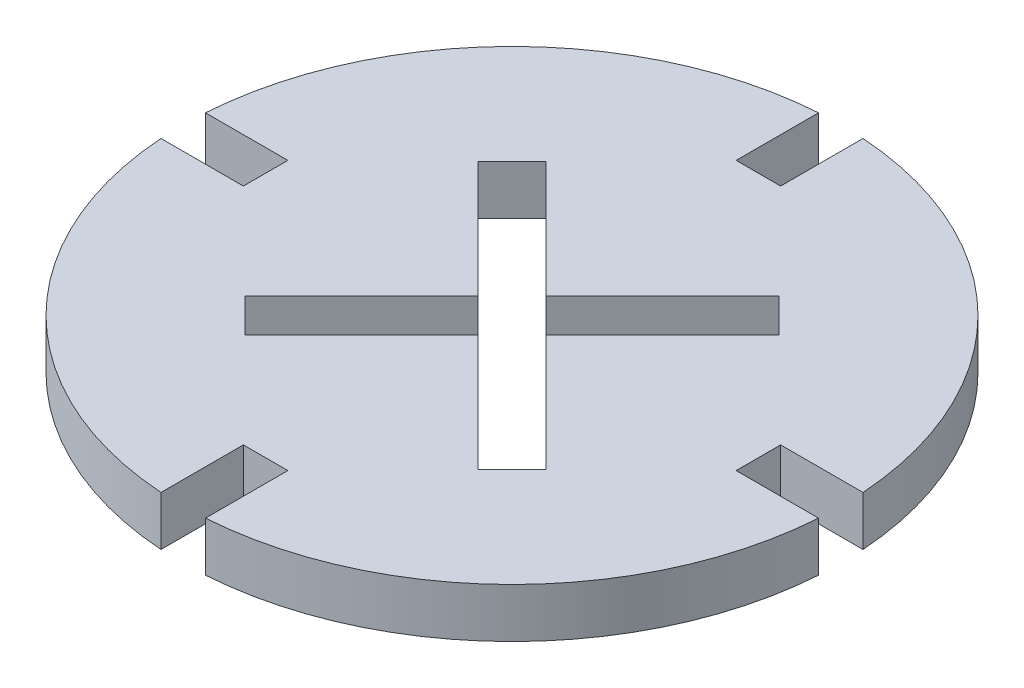
from build123d import *

# Parameters (mm, degrees)
BOSS_EXTRUDE1_DEPTH = 3
CUT_EXTRUDE1_REACH  = 5


with BuildPart() as part:
    # Sketch1 → Boss-Extrude1 (new body)
    with BuildSketch(Plane(origin=(0, 0, 0), x_dir=(1, 0, 0), z_dir=(0, 1, 0))):
        with BuildLine():
            Line((1.35, 14.954385483), (-1.35, 14.954385483))
            Line((-1.35, 14.954385483), (-1.35, 19.954385483))
            ThreePointArc((-1.35, 19.954385483), (-14.142135624, 14.142135624), (-19.954385483, 1.35))
            Line((-19.954385483, 1.35), (-14.954385483, 1.35))
            Line((-14.954385483, 1.35), (-14.954385483, -1.35))
            Line((-14.954385483, -1.35), (-19.954385483, -1.35))
            ThreePointArc((-19.954385483, -1.35), (-14.142135624, -14.142135624), (-1.35, -19.954385483))
            Line((-1.35, -19.954385483), (-1.35, -14.954385483))
            Line((-1.35, -14.954385483), (1.35, -14.954385483))
            Line((1.35, -14.954385483), (1.35, -19.954385483))
            ThreePointArc((1.35, -19.954385483), (14.142135624, -14.142135624), (19.954385483, -1.35))
            Line((19.954385483, -1.35), (14.954385483, -1.35))
            Line((14.954385483, -1.35), (14.954385483, 1.35))
            Line((14.954385483, 1.35), (19.954385483, 1.35))
            ThreePointArc((19.954385483, 1.35), (14.142135624, 14.142135624), (1.35, 19.954385483))
            Line((1.35, 19.954385483), (1.35, 14.954385483))
        make_face()
    extrude(amount=BOSS_EXTRUDE1_DEPTH)

    # Sketch3 → Cut-Extrude1 (cut, up to next)
    with BuildSketch(Plane(origin=(0, 3, 0), x_dir=(1, 0, 0), z_dir=(0, 1, 0)), mode=Mode.PRIVATE) as cut_extrude1_sk1:
        Polygon((0, 2.050609665), (7.071067812, 9.121677477), (9.121677477, 7.071067812), (2.050609665, 0), (9.121677477, -7.071067812), (7.071067812, -9.121677477), (0, -2.050609665), (-7.071067812, -9.121677477), (-9.121677477, -7.071067812), (-2.050609665, 0), (-9.121677477, 7.071067812), (-7.071067812, 9.121677477), align=None)
    cut_extrude1_tool1 = extrude(cut_extrude1_sk1.sketch, amount=-CUT_EXTRUDE1_REACH, mode=Mode.PRIVATE) & part.part
    add(cut_extrude1_tool1.solids().sort_by_distance((0, 3, 0))[0], mode=Mode.SUBTRACT)


solid = part.part
